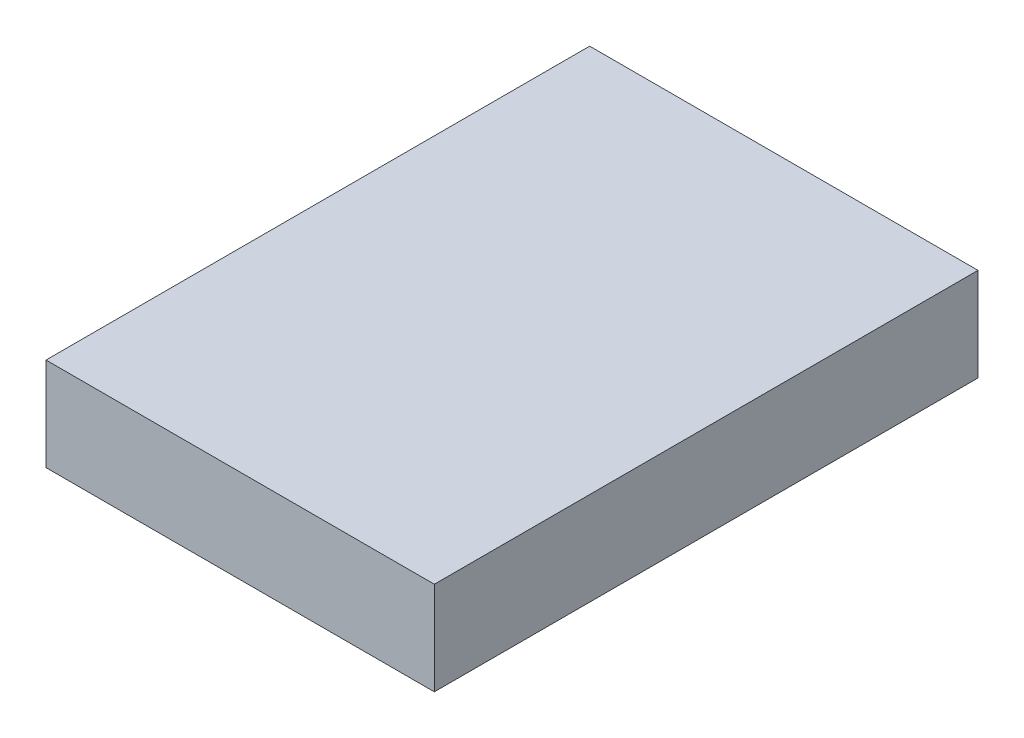
from build123d import *

# Parameters (mm, degrees)
SKETCH_1_W      = 12.5
SKETCH_1_H      = 17.5
EXTRUDE_1_DEPTH = 3


with BuildPart() as part:
    # 草图1 → 凸台-拉伸1 (new body)
    with BuildSketch(Plane(origin=(0, 0, 0), x_dir=(1, 0, 0), z_dir=(0, 1, 0))):
        Rectangle(SKETCH_1_W, SKETCH_1_H)
    extrude(amount=EXTRUDE_1_DEPTH)


solid = part.part
